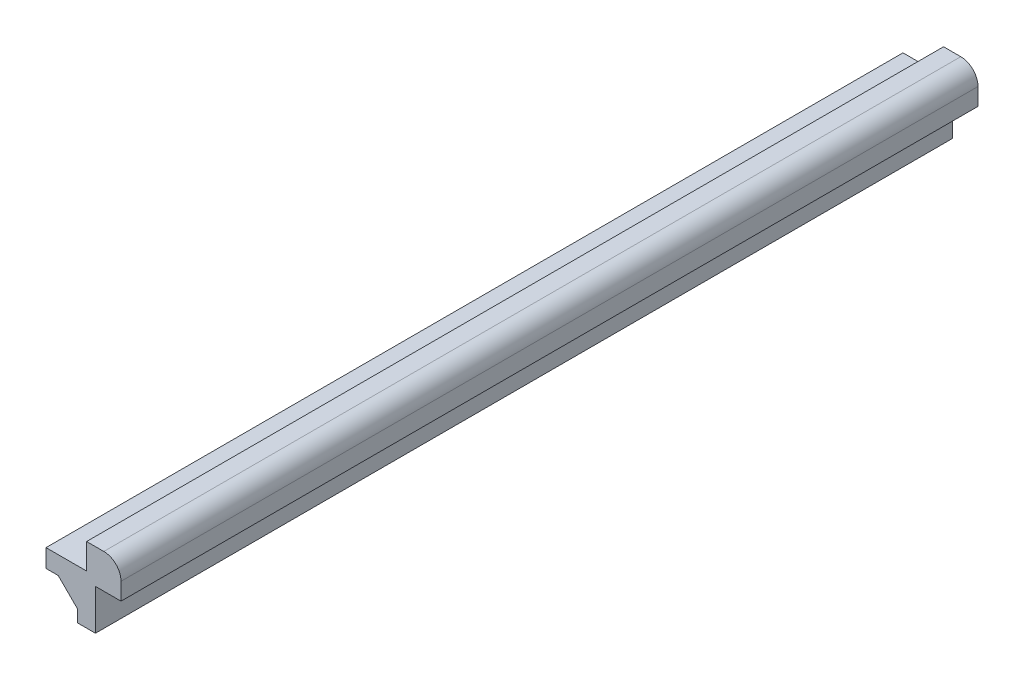
from build123d import *

# Parameters (mm, degrees)
SKETCH7_W           = 4.7625
SKETCH7_H           = 2.12122512
BOSS_EXTRUDE2_DEPTH = 50.27295
SKETCH8_W           = 2.12122512
SKETCH8_H           = 4.7625
BOSS_EXTRUDE3_DEPTH = 50.27295
BOSS_EXTRUDE4_DEPTH = 50.27295


with BuildPart() as part:
    # Sketch7 → Boss-Extrude2 (new, symmetric)
    with BuildSketch(Plane.XY):
        with Locations((-4.92125, -2.560612608)):
            Rectangle(SKETCH7_W, SKETCH7_H)
    extrude(amount=BOSS_EXTRUDE2_DEPTH, both=True)

    # Sketch8 → Boss-Extrude3 (add, symmetric)
    with BuildSketch(Plane.XY):
        with Locations((-2.560612608, -4.92125)):
            Rectangle(SKETCH8_W, SKETCH8_H)
    extrude(amount=BOSS_EXTRUDE3_DEPTH, both=True)

    # Sketch11 → Boss-Extrude4 (add, symmetric)
    with BuildSketch(Plane.XY):
        with BuildLine():
            Line((-2.54, 1.500000048), (-2.54, -1.500000048))
            Line((-2.54, -1.500000048), (-7.3025, -1.500000048))
            Line((-7.3025, -1.500000048), (-7.3025, -3.621225168))
            Line((-7.3025, -3.621225168), (-5.866289198, -3.621225168))
            Line((-5.866289198, -3.621225168), (-3.621225168, -5.866289198))
            Line((-3.621225168, -5.866289198), (-3.621225168, -7.3025))
            Line((-3.621225168, -7.3025), (-1.500000048, -7.3025))
            Line((-1.500000048, -7.3025), (-1.500000048, -2.54))
            Line((-1.500000048, -2.54), (1.500000048, -2.54))
            Line((1.500000048, -2.54), (1.500000048, -0.519999976))
            ThreePointArc((1.500000048, -0.519999976), (0.908355739, 0.908355739), (-0.519999976, 1.500000048))
            Line((-0.519999976, 1.500000048), (-2.54, 1.500000048))
        make_face()
    extrude(amount=BOSS_EXTRUDE4_DEPTH, both=True)


solid = part.part
